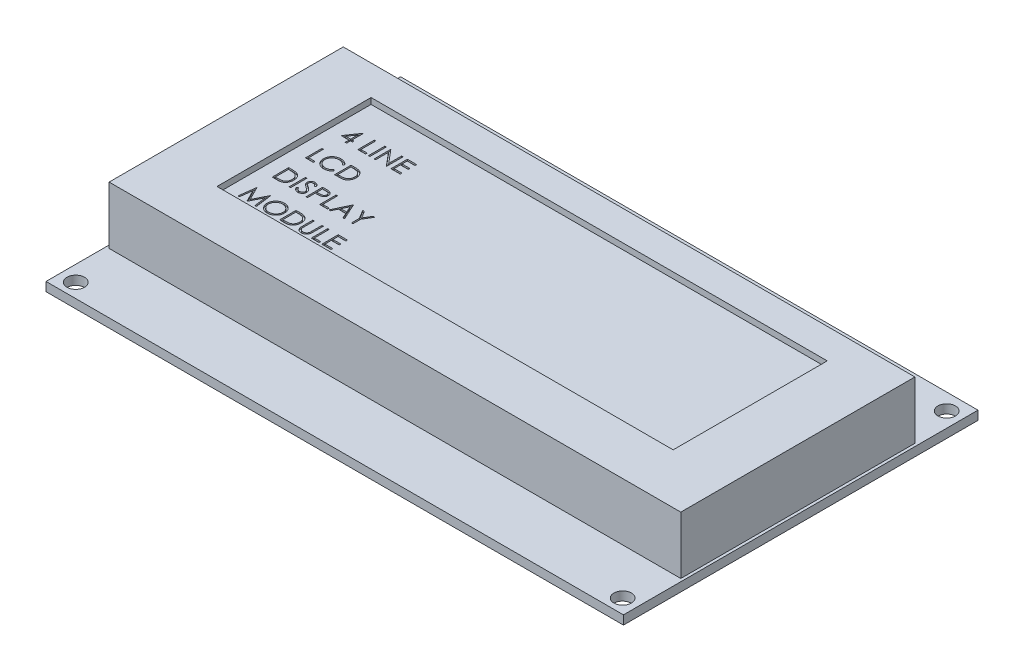
from build123d import *

# Parameters (mm, degrees)
SKETCH1_W           = 97.06
SKETCH1_H           = 39.75
BOSS_EXTRUDE1_DEPTH = 9.76
SKETCH3_W           = 98.044
SKETCH3_H           = 60.198
BOSS_EXTRUDE2_DEPTH = 1.51
SKETCH7_W           = 77.4512
SKETCH7_H           = 26.162
CUT_EXTRUDE3_DEPTH  = 1.016
SKETCH4_R           = 1.4859
CUT_EXTRUDE1_DEPTH  = 2.51
SKETCH5_W           = 0.25074359
SKETCH5_H           = 2.794
CUT_EXTRUDE2_DEPTH  = 0.254
SKETCH6_W           = 41.402
SKETCH6_H           = 2.54
BOSS_EXTRUDE3_DEPTH = 0.0254


with BuildPart() as part:
    # Sketch1 → Boss-Extrude1 (new body)
    with BuildSketch(Plane(origin=(0, 0, 0), x_dir=(1, 0, 0), z_dir=(0, 1, 0))):
        Rectangle(SKETCH1_W, SKETCH1_H)
    extrude(amount=BOSS_EXTRUDE1_DEPTH)

    # Sketch3 → Boss-Extrude2 (add)
    with BuildSketch(Plane.XZ):
        with Locations((-0.016, -0.0122)):
            Rectangle(SKETCH3_W, SKETCH3_H)
    extrude(amount=BOSS_EXTRUDE2_DEPTH)

    # Sketch7 → Cut-Extrude3 (cut)
    with BuildSketch(Plane(origin=(0, 9.76, 0), x_dir=(1, 0, 0), z_dir=(0, 1, 0))):
        with Locations((0, 1.714)):
            Rectangle(SKETCH7_W, SKETCH7_H)
    extrude(amount=-CUT_EXTRUDE3_DEPTH, mode=Mode.SUBTRACT)

    # Sketch4 → Cut-Extrude1 (cut, through all)
    with BuildSketch(Plane(origin=(0, 0, 0), x_dir=(1, 0, 0), z_dir=(0, 1, 0))):
        with Locations((-46.393991932, 27.334150115)):
            Circle(SKETCH4_R)
        with Locations((46.468408068, 27.334150115)):
            Circle(SKETCH4_R)
        with Locations((46.468408068, -27.682249885)):
            Circle(SKETCH4_R)
        with Locations((-46.393991932, -27.682249885)):
            Circle(SKETCH4_R)
    extrude(amount=-CUT_EXTRUDE1_DEPTH, mode=Mode.SUBTRACT)

    # Sketch5 → Cut-Extrude2 (cut)
    with BuildSketch(Plane(origin=(0, 8.744, 0), x_dir=(1, 0, 0), z_dir=(0, 1, 0))):
        Polygon((-35.159137095, 9.89153491), (-35.108204803, 9.89153491), (-35.108204803, 7.957227218), (-34.785820188, 7.957227218), (-34.785820188, 7.670663115), (-35.108204803, 7.670663115), (-35.108204803, 7.025893884), (-35.358948393, 7.025893884), (-35.358948393, 7.670663115), (-36.684307367, 7.670663115), align=None)
        Polygon((-35.358948393, 7.957227218), (-35.358948393, 9.170647089), (-36.191775316, 7.957227218), align=None, mode=Mode.SUBTRACT)
        Polygon((-33.209717624, 9.819893884), (-32.958974034, 9.819893884), (-32.958974034, 7.312457987), (-31.884358649, 7.312457987), (-31.884358649, 7.025893884), (-33.209717624, 7.025893884), align=None)
        with Locations((-31.293320188, 8.422893884)):
            Rectangle(SKETCH5_W, SKETCH5_H)
        Polygon((-30.451538137, 7.025893884), (-30.451538137, 9.819893884), (-30.398926758, 9.819893884), (-28.553050957, 7.620850214), (-28.553050957, 9.819893884), (-28.302307367, 9.819893884), (-28.302307367, 7.025893884), (-28.35939631, 7.025893884), (-30.200794547, 9.219900294), (-30.200794547, 7.025893884), align=None)
        Polygon((-27.585897111, 9.819893884), (-26.009794547, 9.819893884), (-26.009794547, 9.533329782), (-27.335153521, 9.533329782), (-27.335153521, 8.673637474), (-26.009794547, 8.673637474), (-26.009794547, 8.387073371), (-27.335153521, 8.387073371), (-27.335153521, 7.312457987), (-26.009794547, 7.312457987), (-26.009794547, 7.025893884), (-27.585897111, 7.025893884), align=None)
        Polygon((-36.433563778, 4.163227218), (-36.182820188, 4.163227218), (-36.182820188, 1.65579132), (-35.108204803, 1.65579132), (-35.108204803, 1.369227218), (-36.433563778, 1.369227218), align=None)
        with BuildLine():
            Line((-32.063461214, 3.650546128), (-32.282861855, 3.482637474))
            add(Edge.make_bspline(
                [(-32.282861855, 3.482637474), (-32.298512955, 3.501290194), (-32.329604146, 3.538344155), (-32.379624092, 3.590376054), (-32.43175346, 3.63912358), (-32.485972325, 3.684818954), (-32.543256605, 3.725864224), (-32.602218625, 3.764398356), (-32.663844722, 3.798938373), (-32.749063106, 3.840818825), (-32.860541989, 3.884521899), (-33.000876497, 3.921165793), (-33.147370786, 3.94449264), (-33.247314241, 3.947019087), (-33.298149515, 3.948304141)],
                knots=[0, 0, 0, 0, 7.3031e-05, 0.000145078, 0.000216355, 0.000287085, 0.000357615, 0.000427631, 0.000498304, 0.000569392, 0.000712408, 0.000856584, 0.001003817, 0.001156228, 0.001156228, 0.001156228, 0.001156228], degree=3))
            add(Edge.make_bspline(
                [(-33.298149515, 3.948304141), (-33.326156012, 3.947981663), (-33.381909078, 3.947339701), (-33.464650174, 3.938870588), (-33.54584625, 3.926967182), (-33.625444489, 3.909304852), (-33.70334357, 3.88697471), (-33.780052762, 3.86029168), (-33.854461452, 3.827278702), (-33.927598983, 3.790790451), (-33.997671873, 3.749576999), (-34.063973531, 3.704622855), (-34.126262144, 3.656431068), (-34.184586983, 3.604821013), (-34.239007676, 3.550025117), (-34.289129889, 3.491459411), (-34.334780185, 3.429311133), (-34.376863433, 3.364399801), (-34.414552683, 3.29691449), (-34.446108821, 3.226605419), (-34.47405291, 3.154676601), (-34.49616482, 3.08031536), (-34.513666849, 3.004044935), (-34.525743046, 2.925660632), (-34.534115843, 2.845326203), (-34.534754613, 2.790875683), (-34.535076598, 2.76342874)],
                knots=[0, 0, 0, 0, 8.3984e-05, 0.000167189, 0.000249274, 0.000330075, 0.000411568, 0.000492289, 0.000573499, 0.000655599, 0.000737383, 0.000817175, 0.000895765, 0.000973481, 0.001050656, 0.001127268, 0.001204508, 0.001281821, 0.001359234, 0.001436126, 0.001512837, 0.00159057, 0.001668641, 0.001747407, 0.001828384, 0.001910689, 0.001910689, 0.001910689, 0.001910689], degree=3))
            add(Edge.make_bspline(
                [(-34.535076598, 2.76342874), (-34.534069306, 2.722132366), (-34.532091622, 2.641052414), (-34.514490752, 2.522290961), (-34.487744116, 2.408518743), (-34.447657738, 2.300446949), (-34.398228645, 2.196742963), (-34.335770282, 2.099161432), (-34.263432395, 2.006227752), (-34.180191615, 1.920138267), (-34.088863087, 1.841496168), (-33.990875183, 1.772244418), (-33.886471954, 1.71451648), (-33.776806153, 1.666478882), (-33.661033878, 1.629552797), (-33.539363318, 1.603557322), (-33.412059103, 1.586599993), (-33.325070387, 1.584976529), (-33.280798954, 1.584150294)],
                knots=[0, 0, 0, 0, 0.000123819, 0.000243103, 0.00035944, 0.000473821, 0.000588219, 0.000703435, 0.000820659, 0.000940995, 0.001062046, 0.001181765, 0.001300276, 0.001419334, 0.001540405, 0.001664128, 0.001792211, 0.001924955, 0.001924955, 0.001924955, 0.001924955], degree=3))
            add(Edge.make_bspline(
                [(-33.280798954, 1.584150294), (-33.23202155, 1.585498423), (-33.136015951, 1.588151863), (-32.995223875, 1.610630989), (-32.860444696, 1.647079053), (-32.731671162, 1.698087851), (-32.609266305, 1.764397684), (-32.493038571, 1.844783361), (-32.382889854, 1.940009533), (-32.316655065, 2.012719893), (-32.282861855, 2.049816961)],
                knots=[0, 0, 0, 0, 0.000146262, 0.000287878, 0.000426504, 0.000564423, 0.000702406, 0.00084322, 0.000987646, 0.001138088, 0.001138088, 0.001138088, 0.001138088], degree=3))
            Line((-32.282861855, 2.049816961), (-32.063461214, 1.883587394))
            add(Edge.make_bspline(
                [(-32.063461214, 1.883587394), (-32.081117785, 1.860805555), (-32.116346353, 1.815351002), (-32.173390267, 1.751271243), (-32.233483058, 1.69099745), (-32.297071074, 1.635015572), (-32.363422819, 1.582205407), (-32.433729688, 1.534067317), (-32.507067424, 1.489929394), (-32.583187543, 1.449514643), (-32.662009167, 1.413657846), (-32.74343785, 1.382960753), (-32.827122601, 1.356517627), (-32.913067245, 1.334762795), (-33.001450052, 1.317782393), (-33.091952082, 1.306431029), (-33.184768662, 1.298654198), (-33.247387328, 1.297945388), (-33.279119867, 1.297586192)],
                knots=[0, 0, 0, 0, 8.6449e-05, 0.000172484, 0.000257177, 0.000341632, 0.000426509, 0.000511429, 0.00059705, 0.000683178, 0.000769844, 0.000856642, 0.000944087, 0.001033001, 0.001122463, 0.001213892, 0.001306528, 0.001401703, 0.001401703, 0.001401703, 0.001401703], degree=3))
            add(Edge.make_bspline(
                [(-33.279119867, 1.297586192), (-33.309170269, 1.297795337), (-33.368591217, 1.298208895), (-33.456321821, 1.304908242), (-33.541730074, 1.314048404), (-33.624571876, 1.327810954), (-33.705299297, 1.34405155), (-33.783180518, 1.365821805), (-33.858981906, 1.390208768), (-33.932398918, 1.418871206), (-34.003494004, 1.451214696), (-34.072037858, 1.487769443), (-34.137998956, 1.528228052), (-34.202025797, 1.571698708), (-34.263172554, 1.619577732), (-34.321969111, 1.671200182), (-34.378745168, 1.726392068), (-34.413871883, 1.766190486), (-34.431532928, 1.786200375)],
                knots=[0, 0, 0, 0, 9.0127e-05, 0.000178214, 0.000263818, 0.000347735, 0.000430062, 0.000510714, 0.000590185, 0.000668866, 0.000747009, 0.000824379, 0.000901746, 0.000979057, 0.001056421, 0.001134556, 0.001213713, 0.001293755, 0.001293755, 0.001293755, 0.001293755], degree=3))
            add(Edge.make_bspline(
                [(-34.431532928, 1.786200375), (-34.459820696, 1.820958684), (-34.516054718, 1.890055669), (-34.588000763, 2.002043964), (-34.649586554, 2.118967443), (-34.699380361, 2.24144038), (-34.738306954, 2.369187957), (-34.765274, 2.502274571), (-34.782797652, 2.640575928), (-34.78480158, 2.734643353), (-34.785820188, 2.782458387)],
                knots=[0, 0, 0, 0, 0.000134356, 0.00026709, 0.000398523, 0.000530313, 0.000663104, 0.000798557, 0.000937262, 0.001080654, 0.001080654, 0.001080654, 0.001080654], degree=3))
            add(Edge.make_bspline(
                [(-34.785820188, 2.782458387), (-34.784578699, 2.832714827), (-34.782136147, 2.931591233), (-34.761384075, 3.076698783), (-34.728000728, 3.215721357), (-34.68058504, 3.348399432), (-34.620469854, 3.475430862), (-34.546208037, 3.595845241), (-34.458662324, 3.710412651), (-34.358519323, 3.817394713), (-34.248701284, 3.915216128), (-34.13109878, 4.00127628), (-34.005941991, 4.072896491), (-33.874609741, 4.132764856), (-33.736118599, 4.178781608), (-33.590764047, 4.21099498), (-33.43881921, 4.231045615), (-33.335151891, 4.233580338), (-33.28247804, 4.234868243)],
                knots=[0, 0, 0, 0, 0.000150708, 0.000296508, 0.000438773, 0.000578979, 0.000718425, 0.000859629, 0.001002581, 0.001150291, 0.001298563, 0.001443203, 0.00158663, 0.001730409, 0.001875542, 0.002023548, 0.002176485, 0.002334462, 0.002334462, 0.002334462, 0.002334462], degree=3))
            add(Edge.make_bspline(
                [(-33.28247804, 4.234868243), (-33.250375402, 4.234483359), (-33.186831462, 4.23372152), (-33.092831202, 4.22629256), (-33.00131387, 4.213908269), (-32.912216418, 4.197051613), (-32.825105392, 4.176130682), (-32.740646571, 4.14887697), (-32.658344362, 4.117714665), (-32.57871783, 4.081824963), (-32.502149019, 4.041538085), (-32.428661775, 3.997300584), (-32.358839827, 3.949167304), (-32.292191872, 3.897547615), (-32.229832817, 3.841349451), (-32.16999214, 3.78211857), (-32.11470201, 3.718148883), (-32.080572746, 3.67312163), (-32.063461214, 3.650546128)],
                knots=[0, 0, 0, 0, 9.6294e-05, 0.000190604, 0.000282661, 0.000373223, 0.000462545, 0.000551226, 0.000639269, 0.000726445, 0.000813068, 0.000898689, 0.000983609, 0.001067354, 0.001151391, 0.001235293, 0.0013198, 0.001404772, 0.001404772, 0.001404772, 0.001404772], degree=3))
        make_face()
        with BuildLine():
            Line((-31.490333008, 1.369227218), (-31.490333008, 4.163227218))
            Line((-31.490333008, 4.163227218), (-30.926159932, 4.163227218))
            add(Edge.make_bspline(
                [(-30.926159932, 4.163227218), (-30.877090116, 4.16287392), (-30.782287489, 4.162191352), (-30.645291724, 4.157863533), (-30.518536914, 4.150207601), (-30.402439941, 4.139055928), (-30.296682082, 4.125362906), (-30.201559467, 4.10819944), (-30.116580242, 4.087932426), (-30.064316923, 4.070653173), (-30.039602239, 4.062482025)],
                knots=[0, 0, 0, 0, 0.000147209, 0.000284408, 0.000411142, 0.000528095, 0.000634244, 0.000730962, 0.000817976, 0.000896039, 0.000896039, 0.000896039, 0.000896039], degree=3))
            add(Edge.make_bspline(
                [(-30.039602239, 4.062482025), (-30.007275867, 4.050163913), (-29.943356178, 4.025807024), (-29.852345921, 3.97986065), (-29.766669617, 3.927801963), (-29.68586782, 3.86956234), (-29.611786246, 3.803492743), (-29.541530799, 3.732399744), (-29.477975502, 3.65369808), (-29.419773851, 3.569019933), (-29.367298013, 3.479362826), (-29.32168464, 3.384897599), (-29.283802795, 3.286103988), (-29.252355745, 3.18325673), (-29.227571801, 3.076129678), (-29.210662568, 2.964598095), (-29.199509726, 2.849102765), (-29.198388892, 2.770731493), (-29.197820188, 2.7309664)],
                knots=[0, 0, 0, 0, 0.000103725, 0.000205098, 0.00030531, 0.000404275, 0.000503418, 0.000602762, 0.000703812, 0.000806432, 0.000910777, 0.001015164, 0.001120767, 0.00122788, 0.001337582, 0.001450305, 0.001566091, 0.001685354, 0.001685354, 0.001685354, 0.001685354], degree=3))
            add(Edge.make_bspline(
                [(-29.197820188, 2.7309664), (-29.198322284, 2.696431572), (-29.199311716, 2.628377085), (-29.20819609, 2.528079753), (-29.221109415, 2.43075789), (-29.24110184, 2.33687494), (-29.265371732, 2.245608357), (-29.296476258, 2.157930845), (-29.332108137, 2.073038101), (-29.373658811, 1.992077979), (-29.419273963, 1.915375996), (-29.468226234, 1.843070846), (-29.520463413, 1.776194283), (-29.576483618, 1.714543785), (-29.635562921, 1.658212292), (-29.698088115, 1.606729237), (-29.764220539, 1.561101976), (-29.833663991, 1.519537547), (-29.908444306, 1.483279126), (-29.989977909, 1.452600999), (-30.078612512, 1.427178301), (-30.174130557, 1.405967134), (-30.276697082, 1.389141424), (-30.386412645, 1.377864527), (-30.503108677, 1.370238557), (-30.58324001, 1.369570877), (-30.62448405, 1.369227218)],
                knots=[0, 0, 0, 0, 0.000103581, 0.000204118, 0.000301873, 0.00039792, 0.000491876, 0.000584984, 0.000676776, 0.000767889, 0.000857734, 0.000944357, 0.001029673, 0.001112087, 0.001194034, 0.00127437, 0.001354795, 0.001434849, 0.001516954, 0.001603752, 0.001695856, 0.001793352, 0.001897144, 0.002007472, 0.002124116, 0.002247829, 0.002247829, 0.002247829, 0.002247829], degree=3))
            Line((-30.62448405, 1.369227218), (-31.490333008, 1.369227218))
        make_face()
        with BuildLine():
            Line((-31.239589419, 1.65579132), (-30.91888389, 1.65579132))
            add(Edge.make_bspline(
                [(-30.91888389, 1.65579132), (-30.872800156, 1.655989372), (-30.784164259, 1.656370298), (-30.656711561, 1.659712882), (-30.540258123, 1.665174703), (-30.434787409, 1.672818351), (-30.340358971, 1.682931526), (-30.256775463, 1.694207234), (-30.184310871, 1.708255027), (-30.140461487, 1.72098845), (-30.120198393, 1.72687265)],
                knots=[0, 0, 0, 0, 0.000138249, 0.000265904, 0.000382455, 0.000487969, 0.000583093, 0.000667312, 0.000740964, 0.00080424, 0.00080424, 0.00080424, 0.00080424], degree=3))
            add(Edge.make_bspline(
                [(-30.120198393, 1.72687265), (-30.094694472, 1.735854608), (-30.044295791, 1.753603991), (-29.971746719, 1.785980592), (-29.904086413, 1.82433189), (-29.840135724, 1.866962163), (-29.780801817, 1.915375), (-29.725381536, 1.968517669), (-29.673986464, 2.02666063), (-29.627147602, 2.089731716), (-29.585230973, 2.15733837), (-29.54893194, 2.228815942), (-29.517119032, 2.303381264), (-29.492149778, 2.382179376), (-29.472579338, 2.46450583), (-29.458717355, 2.550366418), (-29.450084115, 2.639745107), (-29.449077119, 2.70053626), (-29.448563778, 2.731526096)],
                knots=[0, 0, 0, 0, 8.11e-05, 0.000160263, 0.000237948, 0.000314167, 0.000390565, 0.000467359, 0.000544284, 0.00062309, 0.000702768, 0.000782618, 0.000863387, 0.000945693, 0.001030268, 0.001117037, 0.001206424, 0.001299375, 0.001299375, 0.001299375, 0.001299375], degree=3))
            add(Edge.make_bspline(
                [(-29.448563778, 2.731526096), (-29.448973528, 2.764202708), (-29.449778485, 2.828396203), (-29.459896206, 2.922586489), (-29.474681699, 3.013176472), (-29.496062733, 3.100172208), (-29.523308926, 3.183743424), (-29.55731162, 3.263427913), (-29.596161487, 3.340067228), (-29.642384894, 3.411892479), (-29.693008656, 3.479821093), (-29.749190312, 3.542051388), (-29.810037276, 3.598725124), (-29.874885896, 3.650724907), (-29.945563797, 3.695958709), (-30.020406029, 3.736421163), (-30.100510545, 3.770760134), (-30.156241023, 3.789024004), (-30.184563377, 3.798305743)],
                knots=[0, 0, 0, 0, 9.7987e-05, 0.000192496, 0.000283865, 0.000373187, 0.000460975, 0.000547256, 0.000632865, 0.000718418, 0.000803156, 0.000886776, 0.000969537, 0.001052402, 0.001135769, 0.001220909, 0.001307408, 0.001396793, 0.001396793, 0.001396793, 0.001396793], degree=3))
            add(Edge.make_bspline(
                [(-30.184563377, 3.798305743), (-30.207993978, 3.804784972), (-30.257813864, 3.818561589), (-30.339110853, 3.833589615), (-30.43060649, 3.846844749), (-30.532706994, 3.858067081), (-30.645295981, 3.866119646), (-30.768460042, 3.872163718), (-30.902252412, 3.87624027), (-30.994999269, 3.876518638), (-31.043136294, 3.876663115)],
                knots=[0, 0, 0, 0, 7.29e-05, 0.000155006, 0.000247774, 0.000350251, 0.000463063, 0.00058635, 0.000720174, 0.00086458, 0.00086458, 0.00086458, 0.00086458], degree=3))
            Line((-31.043136294, 3.876663115), (-31.239589419, 3.876663115))
            Line((-31.239589419, 3.876663115), (-31.239589419, 1.65579132))
        make_face(mode=Mode.SUBTRACT)
        with BuildLine():
            Line((-36.433563778, -4.287439449), (-36.433563778, -1.493439449))
            Line((-36.433563778, -1.493439449), (-35.869390701, -1.493439449))
            add(Edge.make_bspline(
                [(-35.869390701, -1.493439449), (-35.820320886, -1.493792746), (-35.725518258, -1.494475315), (-35.588522493, -1.498803134), (-35.461767684, -1.506459066), (-35.34567071, -1.517610739), (-35.239912851, -1.531303761), (-35.144790236, -1.548467226), (-35.059811011, -1.56873424), (-35.007547692, -1.586013494), (-34.982833008, -1.594184641)],
                knots=[0, 0, 0, 0, 0.000147209, 0.000284408, 0.000411142, 0.000528095, 0.000634244, 0.000730962, 0.000817976, 0.000896039, 0.000896039, 0.000896039, 0.000896039], degree=3))
            add(Edge.make_bspline(
                [(-34.982833008, -1.594184641), (-34.950506637, -1.606502753), (-34.886586948, -1.630859643), (-34.79557669, -1.676806016), (-34.709900386, -1.728864704), (-34.629098589, -1.787104327), (-34.555017015, -1.853173924), (-34.484761568, -1.924266923), (-34.421206272, -2.002968587), (-34.36300462, -2.087646734), (-34.310528783, -2.177303841), (-34.264915409, -2.271769068), (-34.227033564, -2.370562679), (-34.195586514, -2.473409937), (-34.170802571, -2.580536988), (-34.153893337, -2.692068572), (-34.142740495, -2.807563902), (-34.141619661, -2.885935174), (-34.141050957, -2.925700266)],
                knots=[0, 0, 0, 0, 0.000103725, 0.000205098, 0.00030531, 0.000404275, 0.000503418, 0.000602762, 0.000703812, 0.000806432, 0.000910777, 0.001015164, 0.001120767, 0.00122788, 0.001337582, 0.001450305, 0.001566091, 0.001685354, 0.001685354, 0.001685354, 0.001685354], degree=3))
            add(Edge.make_bspline(
                [(-34.141050957, -2.925700266), (-34.141553053, -2.960235095), (-34.142542485, -3.028289582), (-34.151426859, -3.128586914), (-34.164340184, -3.225908777), (-34.184332609, -3.319791727), (-34.208602502, -3.41105831), (-34.239707027, -3.498735821), (-34.275338906, -3.583628565), (-34.31688958, -3.664588687), (-34.362504732, -3.741290671), (-34.411457003, -3.813595821), (-34.463694182, -3.880472384), (-34.519714388, -3.942122882), (-34.57879369, -3.998454375), (-34.641318885, -4.049937429), (-34.707451309, -4.095564691), (-34.77689476, -4.137129119), (-34.851675076, -4.17338754), (-34.933208678, -4.204065668), (-35.021843282, -4.229488366), (-35.117361326, -4.250699533), (-35.219927851, -4.267525242), (-35.329643414, -4.27880214), (-35.446339446, -4.286428109), (-35.526470779, -4.28709579), (-35.567714819, -4.287439449)],
                knots=[0, 0, 0, 0, 0.000103581, 0.000204118, 0.000301873, 0.00039792, 0.000491876, 0.000584984, 0.000676776, 0.000767889, 0.000857734, 0.000944357, 0.001029673, 0.001112087, 0.001194034, 0.00127437, 0.001354795, 0.001434849, 0.001516954, 0.001603752, 0.001695856, 0.001793352, 0.001897144, 0.002007472, 0.002124116, 0.002247829, 0.002247829, 0.002247829, 0.002247829], degree=3))
            Line((-35.567714819, -4.287439449), (-36.433563778, -4.287439449))
        make_face()
        with BuildLine():
            Line((-36.182820188, -4.000875347), (-35.862114659, -4.000875347))
            add(Edge.make_bspline(
                [(-35.862114659, -4.000875347), (-35.816030925, -4.000677295), (-35.727395029, -4.000296369), (-35.59994233, -3.996953784), (-35.483488892, -3.991491963), (-35.378018178, -3.983848315), (-35.28358974, -3.973735141), (-35.200006232, -3.962459433), (-35.127541641, -3.948411639), (-35.083692256, -3.935678216), (-35.063429162, -3.929794016)],
                knots=[0, 0, 0, 0, 0.000138249, 0.000265904, 0.000382455, 0.000487969, 0.000583093, 0.000667312, 0.000740964, 0.00080424, 0.00080424, 0.00080424, 0.00080424], degree=3))
            add(Edge.make_bspline(
                [(-35.063429162, -3.929794016), (-35.037925241, -3.920812058), (-34.98752656, -3.903062676), (-34.914977488, -3.870686074), (-34.847317182, -3.832334776), (-34.783366493, -3.789704504), (-34.724032586, -3.741291667), (-34.668612306, -3.688148997), (-34.617217233, -3.630006037), (-34.570378371, -3.56693495), (-34.528461742, -3.499328296), (-34.49216271, -3.427850724), (-34.460349801, -3.353285402), (-34.435380548, -3.274487291), (-34.415810107, -3.192160837), (-34.401948125, -3.106300248), (-34.393314885, -3.01692156), (-34.392307889, -2.956130407), (-34.391794547, -2.925140571)],
                knots=[0, 0, 0, 0, 8.11e-05, 0.000160263, 0.000237948, 0.000314167, 0.000390565, 0.000467359, 0.000544284, 0.00062309, 0.000702768, 0.000782618, 0.000863387, 0.000945693, 0.001030268, 0.001117037, 0.001206424, 0.001299375, 0.001299375, 0.001299375, 0.001299375], degree=3))
            add(Edge.make_bspline(
                [(-34.391794547, -2.925140571), (-34.392204297, -2.892463958), (-34.393009254, -2.828270464), (-34.403126975, -2.734080177), (-34.417912468, -2.643490195), (-34.439293502, -2.556494459), (-34.466539695, -2.472923243), (-34.500542389, -2.393238754), (-34.539392256, -2.316599438), (-34.585615663, -2.244774187), (-34.636239425, -2.176845574), (-34.692421081, -2.114615279), (-34.753268045, -2.057941543), (-34.818116665, -2.00594176), (-34.888794567, -1.960707957), (-34.963636799, -1.920245504), (-35.043741314, -1.885906532), (-35.099471792, -1.867642663), (-35.127794146, -1.858360923)],
                knots=[0, 0, 0, 0, 9.7987e-05, 0.000192496, 0.000283865, 0.000373187, 0.000460975, 0.000547256, 0.000632865, 0.000718418, 0.000803156, 0.000886776, 0.000969537, 0.001052402, 0.001135769, 0.001220909, 0.001307408, 0.001396793, 0.001396793, 0.001396793, 0.001396793], degree=3))
            add(Edge.make_bspline(
                [(-35.127794146, -1.858360923), (-35.151224747, -1.851881695), (-35.201044633, -1.838105078), (-35.282341622, -1.823077052), (-35.373837259, -1.809821917), (-35.475937763, -1.798599585), (-35.58852675, -1.790547021), (-35.711690811, -1.784502949), (-35.845483181, -1.780426397), (-35.938230038, -1.780148029), (-35.986367063, -1.780003552)],
                knots=[0, 0, 0, 0, 7.29e-05, 0.000155006, 0.000247774, 0.000350251, 0.000463063, 0.00058635, 0.000720174, 0.00086458, 0.00086458, 0.00086458, 0.00086458], degree=3))
            Line((-35.986367063, -1.780003552), (-36.182820188, -1.780003552))
            Line((-36.182820188, -1.780003552), (-36.182820188, -4.000875347))
        make_face(mode=Mode.SUBTRACT)
        with Locations((-33.442550957, -2.890439449)):
            Rectangle(SKETCH5_W, SKETCH5_H)
        with BuildLine():
            Line((-32.887333008, -3.74845267), (-32.651141502, -3.606849706))
            add(Edge.make_bspline(
                [(-32.651141502, -3.606849706), (-32.629174086, -3.643622246), (-32.587085366, -3.714077014), (-32.516875052, -3.809279004), (-32.444124951, -3.890194966), (-32.368296323, -3.956354178), (-32.28985202, -4.008441432), (-32.20827995, -4.045324014), (-32.123855001, -4.068327395), (-32.066399327, -4.071121464), (-32.03771522, -4.072516372)],
                knots=[0, 0, 0, 0, 0.000128445, 0.000246096, 0.000354262, 0.000454248, 0.000547235, 0.000635662, 0.000721866, 0.000807808, 0.000807808, 0.000807808, 0.000807808], degree=3))
            add(Edge.make_bspline(
                [(-32.03771522, -4.072516372), (-32.013218338, -4.071834099), (-31.964653211, -4.070481492), (-31.893156952, -4.05748476), (-31.823720622, -4.037517935), (-31.757775326, -4.008922597), (-31.696230998, -3.974326103), (-31.642261539, -3.932538897), (-31.595604842, -3.885754401), (-31.557439509, -3.833560361), (-31.528158361, -3.777427186), (-31.505653035, -3.719810155), (-31.493163797, -3.659804161), (-31.491282434, -3.619402552), (-31.490333008, -3.599013968)],
                knots=[0, 0, 0, 0, 7.3425e-05, 0.000145565, 0.000217295, 0.000289758, 0.000360707, 0.000428548, 0.00049385, 0.000558332, 0.000621677, 0.000683319, 0.000743364, 0.000804534, 0.000804534, 0.000804534, 0.000804534], degree=3))
            add(Edge.make_bspline(
                [(-31.490333008, -3.599013968), (-31.49150993, -3.575751244), (-31.493902438, -3.528461526), (-31.514124197, -3.458691631), (-31.545935282, -3.389645848), (-31.575282375, -3.346936552), (-31.590518505, -3.324763167)],
                knots=[0, 0, 0, 0, 6.9675e-05, 0.000141639, 0.000216263, 0.000296838, 0.000296838, 0.000296838, 0.000296838], degree=3))
            add(Edge.make_bspline(
                [(-31.590518505, -3.324763167), (-31.603028133, -3.308760074), (-31.629290531, -3.275163582), (-31.674439585, -3.225154786), (-31.727418706, -3.173570825), (-31.786414858, -3.118441967), (-31.853577101, -3.062332223), (-31.926801865, -3.002565946), (-32.007958672, -2.941416001), (-32.064876041, -2.900406016), (-32.094244467, -2.879245539)],
                knots=[0, 0, 0, 0, 6.0925e-05, 0.000127904, 0.000201913, 0.000282711, 0.00037007, 0.000464386, 0.000566252, 0.000674846, 0.000674846, 0.000674846, 0.000674846], degree=3))
            add(Edge.make_bspline(
                [(-32.094244467, -2.879245539), (-32.123640537, -2.858307632), (-32.179843584, -2.818275949), (-32.258441664, -2.758864106), (-32.328726301, -2.704545657), (-32.390385105, -2.654809254), (-32.443390954, -2.609648152), (-32.48816154, -2.569496026), (-32.523556377, -2.533266977), (-32.543238575, -2.509764375), (-32.552075396, -2.499212286)],
                knots=[0, 0, 0, 0, 0.000108266, 0.000206996, 0.000295552, 0.000374747, 0.000444621, 0.000504446, 0.00055511, 0.000596391, 0.000596391, 0.000596391, 0.000596391], degree=3))
            add(Edge.make_bspline(
                [(-32.552075396, -2.499212286), (-32.564426908, -2.482766772), (-32.588717814, -2.450424463), (-32.620781762, -2.399873134), (-32.648034568, -2.348125647), (-32.669398555, -2.295042948), (-32.687388897, -2.241370265), (-32.699489257, -2.186407299), (-32.707066103, -2.130400676), (-32.707842026, -2.092710813), (-32.708230444, -2.073843696)],
                knots=[0, 0, 0, 0, 6.1683e-05, 0.000121309, 0.000179388, 0.000236865, 0.000292795, 0.000349011, 0.000405451, 0.000462025, 0.000462025, 0.000462025, 0.000462025], degree=3))
            add(Edge.make_bspline(
                [(-32.708230444, -2.073843696), (-32.707188515, -2.044283356), (-32.705126926, -1.985794507), (-32.687691953, -1.900353324), (-32.660172734, -1.818779367), (-32.621619615, -1.741880238), (-32.57192046, -1.671658252), (-32.514407188, -1.607305657), (-32.445905104, -1.553206966), (-32.37074441, -1.505938826), (-32.28847598, -1.468941536), (-32.202268385, -1.441032685), (-32.111984608, -1.425219237), (-32.05083342, -1.422949899), (-32.019804964, -1.421798423)],
                knots=[0, 0, 0, 0, 8.8609e-05, 0.000175324, 0.000260458, 0.000346313, 0.000432331, 0.000517908, 0.00060427, 0.000693261, 0.000783679, 0.00087413, 0.000964491, 0.001057569, 0.001057569, 0.001057569, 0.001057569], degree=3))
            add(Edge.make_bspline(
                [(-32.019804964, -1.421798423), (-31.986880387, -1.422934026), (-31.921403914, -1.425192377), (-31.825091369, -1.444828235), (-31.732361928, -1.477319), (-31.657767505, -1.514190746), (-31.599386666, -1.551016796), (-31.554864091, -1.584560621), (-31.509747017, -1.62317778), (-31.463671518, -1.666971132), (-31.417418318, -1.71634251), (-31.370300739, -1.770953785), (-31.3222086, -1.830471219), (-31.29127035, -1.872959578), (-31.275409932, -1.894741132)],
                knots=[0, 0, 0, 0, 9.8699e-05, 0.00019628, 0.000293456, 0.000392827, 0.000445155, 0.000500341, 0.000559895, 0.000623237, 0.000690942, 0.00076276, 0.000839593, 0.000920414, 0.000920414, 0.000920414, 0.000920414], degree=3))
            Line((-31.275409932, -1.894741132), (-31.502086614, -2.066567654))
            add(Edge.make_bspline(
                [(-31.502086614, -2.066567654), (-31.515773967, -2.048934568), (-31.542132609, -2.014977367), (-31.582150262, -1.967422437), (-31.619868183, -1.923982539), (-31.657028702, -1.886251462), (-31.691669218, -1.852162959), (-31.725290651, -1.822977828), (-31.757409159, -1.79841011), (-31.797895744, -1.772191565), (-31.848760688, -1.746202173), (-31.912611201, -1.724210138), (-31.97933693, -1.710994468), (-32.024783042, -1.709247111), (-32.047789739, -1.708362526)],
                knots=[0, 0, 0, 0, 6.6958e-05, 0.000128945, 0.000186442, 0.00023948, 0.00028777, 0.000332208, 0.000372955, 0.000408971, 0.000476806, 0.000543712, 0.000610999, 0.000679987, 0.000679987, 0.000679987, 0.000679987], degree=3))
            add(Edge.make_bspline(
                [(-32.047789739, -1.708362526), (-32.076652975, -1.709329809), (-32.132313005, -1.711195122), (-32.211335496, -1.731567362), (-32.282457904, -1.763643967), (-32.343568723, -1.80859941), (-32.394449041, -1.861861825), (-32.43125437, -1.923153288), (-32.45340693, -1.990833869), (-32.456110149, -2.038045808), (-32.457486855, -2.06209009)],
                knots=[0, 0, 0, 0, 8.6413e-05, 0.000166639, 0.000243022, 0.000319149, 0.0003928, 0.000462582, 0.000531966, 0.000603976, 0.000603976, 0.000603976, 0.000603976], degree=3))
            add(Edge.make_bspline(
                [(-32.457486855, -2.06209009), (-32.457173027, -2.077059128), (-32.456544859, -2.10702168), (-32.447783835, -2.151287758), (-32.436528542, -2.19544201), (-32.418692738, -2.239285923), (-32.394069373, -2.283586277), (-32.36173467, -2.329105916), (-32.321011472, -2.376246051), (-32.289816851, -2.406906109), (-32.273347031, -2.423093696)],
                knots=[0, 0, 0, 0, 4.4832e-05, 8.9736e-05, 0.000134947, 0.000181405, 0.000231256, 0.000286691, 0.000348613, 0.000417873, 0.000417873, 0.000417873, 0.000417873], degree=3))
            add(Edge.make_bspline(
                [(-32.273347031, -2.423093696), (-32.267231067, -2.428551596), (-32.252700936, -2.441518317), (-32.22613724, -2.462746555), (-32.191058332, -2.488932539), (-32.14838022, -2.521332814), (-32.097315989, -2.558917273), (-32.037860023, -2.601205351), (-31.970675074, -2.649569857), (-31.922999922, -2.683383277), (-31.897791342, -2.701262366)],
                knots=[0, 0, 0, 0, 2.4588e-05, 5.8416e-05, 0.000101961, 0.000155916, 0.000219164, 0.000292165, 0.000374796, 0.000467511, 0.000467511, 0.000467511, 0.000467511], degree=3))
            add(Edge.make_bspline(
                [(-31.897791342, -2.701262366), (-31.86746773, -2.723328068), (-31.808750258, -2.766055243), (-31.725203607, -2.830249931), (-31.649451236, -2.893033321), (-31.581227181, -2.954004474), (-31.519857443, -3.0127009), (-31.466022874, -3.069828765), (-31.419174934, -3.124978791), (-31.368739867, -3.195685012), (-31.317204282, -3.282523398), (-31.272946118, -3.388917512), (-31.245039369, -3.495725203), (-31.241389993, -3.567512512), (-31.239589419, -3.602931837)],
                knots=[0, 0, 0, 0, 0.000112504, 0.000217849, 0.000316026, 0.000407592, 0.0004923, 0.000570698, 0.000643005, 0.000709174, 0.000831085, 0.000945005, 0.001054009, 0.00116017, 0.00116017, 0.00116017, 0.00116017], degree=3))
            add(Edge.make_bspline(
                [(-31.239589419, -3.602931837), (-31.240114003, -3.627980738), (-31.241152984, -3.677592106), (-31.253096067, -3.75043973), (-31.270594223, -3.821192487), (-31.296967375, -3.888975815), (-31.329156776, -3.955029777), (-31.370002061, -4.017621684), (-31.417346538, -4.078136849), (-31.471656921, -4.134961613), (-31.531086021, -4.187126548), (-31.59389809, -4.233530148), (-31.660195937, -4.272221718), (-31.729619905, -4.30379459), (-31.802185942, -4.328488375), (-31.877869641, -4.346380248), (-31.95679576, -4.357361236), (-32.010440944, -4.358500997), (-32.03771522, -4.359080475)],
                knots=[0, 0, 0, 0, 7.5074e-05, 0.000148691, 0.000220909, 0.000293361, 0.00036645, 0.000440971, 0.000517108, 0.000596682, 0.000676397, 0.000754087, 0.000830594, 0.000906236, 0.000982521, 0.001060173, 0.001139249, 0.001221034, 0.001221034, 0.001221034, 0.001221034], degree=3))
            add(Edge.make_bspline(
                [(-32.03771522, -4.359080475), (-32.058818177, -4.358672406), (-32.10075832, -4.357861407), (-32.162792689, -4.350691779), (-32.223573836, -4.34054788), (-32.282339065, -4.324443208), (-32.339845502, -4.304903587), (-32.395843037, -4.280844587), (-32.45035881, -4.252012741), (-32.503698332, -4.219047512), (-32.555725944, -4.180683701), (-32.605953657, -4.136000859), (-32.656029469, -4.086231333), (-32.704475351, -4.030023586), (-32.752271227, -3.968285699), (-32.798474734, -3.900440048), (-32.844042254, -3.826856184), (-32.87263323, -3.775075312), (-32.887333008, -3.74845267)],
                knots=[0, 0, 0, 0, 6.3285e-05, 0.000125773, 0.000187149, 0.00024797, 0.000308327, 0.000369251, 0.000430589, 0.000493179, 0.00055721, 0.000624236, 0.000694682, 0.000768869, 0.000846674, 0.000928799, 0.001015003, 0.001106225, 0.001106225, 0.001106225, 0.001106225], degree=3))
        make_face()
        with BuildLine():
            Line((-30.666461214, -1.493439449), (-30.118519307, -1.493439449))
            add(Edge.make_bspline(
                [(-30.118519307, -1.493439449), (-30.080831515, -1.493480877), (-30.008620032, -1.493560255), (-29.905070356, -1.495966884), (-29.81102453, -1.499181334), (-29.72668534, -1.50363728), (-29.651793289, -1.508903244), (-29.586687262, -1.516289015), (-29.530855513, -1.524000691), (-29.497402193, -1.531840979), (-29.482145508, -1.535416613)],
                knots=[0, 0, 0, 0, 0.00011306, 0.000216628, 0.000310717, 0.000395349, 0.000469999, 0.000535886, 0.000591928, 0.000638916, 0.000638916, 0.000638916, 0.000638916], degree=3))
            add(Edge.make_bspline(
                [(-29.482145508, -1.535416613), (-29.462832156, -1.540702821), (-29.424660546, -1.551150674), (-29.369657828, -1.572076715), (-29.317327129, -1.596889163), (-29.267488908, -1.625167588), (-29.2207556, -1.658125264), (-29.176429954, -1.694426204), (-29.134903147, -1.734908524), (-29.096408699, -1.779118178), (-29.061056778, -1.826312997), (-29.030618397, -1.877197508), (-29.005131347, -1.930915195), (-28.983271673, -1.987428691), (-28.967538695, -2.047212566), (-28.955686627, -2.109851422), (-28.94816388, -2.175338543), (-28.947443378, -2.220090335), (-28.947076598, -2.242871741)],
                knots=[0, 0, 0, 0, 6.0044e-05, 0.000118673, 0.000176257, 0.000233669, 0.000290342, 0.000347601, 0.000405388, 0.000464094, 0.000523311, 0.000582055, 0.000641636, 0.00070151, 0.000763558, 0.000826786, 0.000892674, 0.000960993, 0.000960993, 0.000960993, 0.000960993], degree=3))
            add(Edge.make_bspline(
                [(-28.947076598, -2.242871741), (-28.947413016, -2.265844629), (-28.948071239, -2.310792636), (-28.955971302, -2.376549656), (-28.966612604, -2.439389422), (-28.982975108, -2.499172601), (-29.004405625, -2.555544162), (-29.029545281, -2.609365568), (-29.05986699, -2.659721169), (-29.094708035, -2.706793776), (-29.133466079, -2.750627575), (-29.175977139, -2.790904917), (-29.222069591, -2.827390037), (-29.271596951, -2.86016473), (-29.325042059, -2.888468971), (-29.381594338, -2.913820374), (-29.44174534, -2.935111501), (-29.483369964, -2.946311498), (-29.504533329, -2.952005956)],
                knots=[0, 0, 0, 0, 6.8879e-05, 0.000134766, 0.000198444, 0.000259952, 0.00032035, 0.000379184, 0.000437928, 0.000496362, 0.000554649, 0.000613243, 0.000671808, 0.000730797, 0.000791146, 0.000853032, 0.000916584, 0.000982316, 0.000982316, 0.000982316, 0.000982316], degree=3))
            add(Edge.make_bspline(
                [(-29.504533329, -2.952005956), (-29.522037606, -2.955728347), (-29.560399248, -2.963886183), (-29.623577753, -2.972993392), (-29.697136098, -2.980766779), (-29.780973884, -2.986595173), (-29.875015856, -2.991584753), (-29.979312889, -2.995550711), (-30.094069715, -2.997729914), (-30.174114817, -2.997842307), (-30.215906326, -2.997900988)],
                knots=[0, 0, 0, 0, 5.3675e-05, 0.000117633, 0.00019137, 0.00027555, 0.000369714, 0.000473891, 0.00058865, 0.000714023, 0.000714023, 0.000714023, 0.000714023], degree=3))
            Line((-30.215906326, -2.997900988), (-30.415717624, -2.997900988))
            Line((-30.415717624, -2.997900988), (-30.415717624, -4.287439449))
            Line((-30.415717624, -4.287439449), (-30.666461214, -4.287439449))
            Line((-30.666461214, -4.287439449), (-30.666461214, -1.493439449))
        make_face()
        with BuildLine():
            Line((-30.415717624, -1.780003552), (-30.415717624, -2.711336885))
            Line((-30.415717624, -2.711336885), (-29.926543746, -2.717493536))
            add(Edge.make_bspline(
                [(-29.926543746, -2.717493536), (-29.902659096, -2.71750588), (-29.856550273, -2.717529711), (-29.789944328, -2.714348364), (-29.7281496, -2.710675824), (-29.671355902, -2.705298633), (-29.619537632, -2.697697949), (-29.572608387, -2.690025036), (-29.530932059, -2.678924583), (-29.482157439, -2.663978225), (-29.427807476, -2.638486874), (-29.36868041, -2.601486419), (-29.318571547, -2.554323133), (-29.275210027, -2.501294745), (-29.24079922, -2.442302125), (-29.215608523, -2.379182523), (-29.200807381, -2.312583262), (-29.198822689, -2.267010617), (-29.197820188, -2.243991132)],
                knots=[0, 0, 0, 0, 7.1643e-05, 0.000138306, 0.000199997, 0.000257359, 0.000309363, 0.000357121, 0.000399882, 0.000438647, 0.000510027, 0.000579269, 0.000647001, 0.000715445, 0.000784176, 0.000851005, 0.000918633, 0.00098766, 0.00098766, 0.00098766, 0.00098766], degree=3))
            add(Edge.make_bspline(
                [(-29.197820188, -2.243991132), (-29.198828141, -2.221528559), (-29.200831826, -2.176875743), (-29.215724535, -2.111433269), (-29.240750244, -2.048978824), (-29.275441023, -1.990725453), (-29.317543513, -1.937887876), (-29.366477903, -1.891988741), (-29.422129004, -1.855090616), (-29.47389642, -1.831275133), (-29.519878624, -1.816734139), (-29.559818423, -1.806560115), (-29.604914122, -1.798437074), (-29.6551804, -1.791859597), (-29.710227656, -1.786228919), (-29.770528813, -1.782408342), (-29.835855442, -1.78017198), (-29.881206509, -1.780061054), (-29.904715621, -1.780003552)],
                knots=[0, 0, 0, 0, 6.7352e-05, 0.000133888, 0.000200197, 0.000268445, 0.000336537, 0.000402277, 0.000468872, 0.000535991, 0.000572453, 0.000613448, 0.000659554, 0.000709818, 0.00076551, 0.000825525, 0.000891048, 0.000961572, 0.000961572, 0.000961572, 0.000961572], degree=3))
            Line((-29.904715621, -1.780003552), (-30.415717624, -1.780003552))
        make_face(mode=Mode.SUBTRACT)
        Polygon((-28.373948393, -1.493439449), (-28.123204803, -1.493439449), (-28.123204803, -4.000875347), (-27.048589419, -4.000875347), (-27.048589419, -4.287439449), (-28.373948393, -4.287439449), align=None)
        Polygon((-25.436666342, -1.493439449), (-24.14712788, -4.287439449), (-24.419699595, -4.287439449), (-24.832754883, -3.391926629), (-26.099345829, -3.391926629), (-26.524154723, -4.287439449), (-26.797845829, -4.287439449), (-25.472486855, -1.493439449), align=None)
        Polygon((-25.457375076, -2.038023183), (-25.963339819, -3.105362526), (-24.964843024, -3.105362526), align=None, mode=Mode.SUBTRACT)
        Polygon((-23.860563778, -1.493439449), (-23.57343998, -1.493439449), (-22.839119467, -2.693986324), (-22.105918345, -1.493439449), (-21.818794547, -1.493439449), (-22.714307367, -2.959281997), (-22.714307367, -4.287439449), (-22.965050957, -4.287439449), (-22.965050957, -2.959281997), align=None)
        Polygon((-36.576845829, -9.944106116), (-36.208006486, -7.150106116), (-36.172185973, -7.150106116), (-35.018653521, -9.442618936), (-33.867919547, -7.150106116), (-33.831539339, -7.150106116), (-33.460461214, -9.944106116), (-33.712324194, -9.944106116), (-33.979858649, -7.933679834), (-34.988429964, -9.944106116), (-35.04495921, -9.944106116), (-36.057448393, -7.92920227), (-36.324423153, -9.944106116), align=None)
        with BuildLine():
            add(Edge.make_bspline(
                [(-31.57988429, -7.07846509), (-31.528148905, -7.07977546), (-31.426536341, -7.082349134), (-31.277197122, -7.102050109), (-31.134627209, -7.136133229), (-30.997665218, -7.181526136), (-30.867949396, -7.242079608), (-30.744503378, -7.315270552), (-30.627620879, -7.40186576), (-30.518877296, -7.501195834), (-30.419365433, -7.609270511), (-30.331692997, -7.724605163), (-30.258216949, -7.846502435), (-30.197877895, -7.974596024), (-30.150540662, -8.108596238), (-30.117875574, -8.249217462), (-30.097009862, -8.395548574), (-30.094570479, -8.495355734), (-30.093333008, -8.545986725)],
                knots=[0, 0, 0, 0, 0.000155181, 0.000304788, 0.000450864, 0.000594404, 0.000736891, 0.000879433, 0.001024285, 0.001172472, 0.001320623, 0.001464466, 0.001606336, 0.001746794, 0.001888582, 0.002031805, 0.002179269, 0.002331095, 0.002331095, 0.002331095, 0.002331095], degree=3))
            add(Edge.make_bspline(
                [(-30.093333008, -8.545986725), (-30.094570297, -8.596244755), (-30.097009137, -8.695309154), (-30.117899299, -8.840711664), (-30.150661743, -8.980484066), (-30.197438305, -9.114393024), (-30.25748973, -9.242579799), (-30.331455029, -9.364707099), (-30.418580898, -9.480814961), (-30.517733453, -9.589631414), (-30.625822171, -9.689415109), (-30.741757418, -9.776363492), (-30.862931857, -9.851182121), (-30.990904807, -9.91088086), (-31.123979065, -9.95859593), (-31.263345639, -9.991128173), (-31.408351488, -10.012112744), (-31.507235941, -10.014522382), (-31.55749647, -10.015747141)],
                knots=[0, 0, 0, 0, 0.000150708, 0.000297063, 0.000439741, 0.000580817, 0.000721781, 0.00086365, 0.001008387, 0.001156575, 0.001304726, 0.001449016, 0.001590697, 0.001731155, 0.001871888, 0.002014022, 0.002159823, 0.00231053, 0.00231053, 0.00231053, 0.00231053], degree=3))
            add(Edge.make_bspline(
                [(-31.55749647, -10.015747141), (-31.608127198, -10.014510288), (-31.70793384, -10.012072121), (-31.854448833, -9.991171879), (-31.995168838, -9.958489021), (-32.129691437, -9.911781774), (-32.258091647, -9.851417619), (-32.380620587, -9.777812181), (-32.496786443, -9.690474023), (-32.605626112, -9.59135362), (-32.705211615, -9.483448101), (-32.79203267, -9.367828984), (-32.865654661, -9.2467646), (-32.925816133, -9.119918976), (-32.973445418, -8.987905316), (-33.005939493, -8.849843017), (-33.026963107, -8.706519195), (-33.029385782, -8.608934435), (-33.03061506, -8.559419417)],
                knots=[0, 0, 0, 0, 0.000151826, 0.00029929, 0.000443057, 0.000584661, 0.000725626, 0.000867975, 0.001012712, 0.001160899, 0.00130905, 0.001452556, 0.001593947, 0.001733393, 0.001873072, 0.002014117, 0.002158255, 0.002306726, 0.002306726, 0.002306726, 0.002306726], degree=3))
            add(Edge.make_bspline(
                [(-33.03061506, -8.559419417), (-33.030188268, -8.526184652), (-33.029340068, -8.460134393), (-33.019128643, -8.362051742), (-33.004311102, -8.265546457), (-32.983075175, -8.170892963), (-32.955301484, -8.078322965), (-32.922530237, -7.987198042), (-32.882504315, -7.898441664), (-32.837256964, -7.811633368), (-32.786755966, -7.728126371), (-32.730975153, -7.649192212), (-32.671873776, -7.574168525), (-32.607082199, -7.50499946), (-32.538735814, -7.439672821), (-32.465725897, -7.379192526), (-32.388497945, -7.323013208), (-32.306719657, -7.272385656), (-32.222406097, -7.226596678), (-32.135491321, -7.187303578), (-32.04715576, -7.15357915), (-31.956985679, -7.126245189), (-31.865220523, -7.1046659), (-31.771660013, -7.089971573), (-31.676378684, -7.079734103), (-31.612187477, -7.078889914), (-31.57988429, -7.07846509)],
                knots=[0, 0, 0, 0, 9.9665e-05, 0.000198073, 0.000295519, 0.00039247, 0.000488806, 0.000585302, 0.000682763, 0.000780648, 0.000878843, 0.00097527, 0.00107046, 0.001165115, 0.001259336, 0.00135393, 0.001449315, 0.001545604, 0.001642267, 0.001736947, 0.001831541, 0.001925733, 0.002019409, 0.002114092, 0.002209715, 0.002306583, 0.002306583, 0.002306583, 0.002306583], degree=3))
        make_face()
        with BuildLine():
            add(Edge.make_bspline(
                [(-31.567570989, -7.365029193), (-31.594085757, -7.365352411), (-31.646861809, -7.365995757), (-31.72532095, -7.374470131), (-31.802748225, -7.386548105), (-31.879159624, -7.403776325), (-31.954235434, -7.42724916), (-32.02867545, -7.454263874), (-32.101800859, -7.487170082), (-32.173370253, -7.524348406), (-32.242753316, -7.565499173), (-32.308222884, -7.610978921), (-32.369948446, -7.659721093), (-32.427778871, -7.711839441), (-32.481544349, -7.76759938), (-32.532303108, -7.826155582), (-32.578020597, -7.889181748), (-32.619919083, -7.954968799), (-32.657412839, -8.023431044), (-32.690753525, -8.093847717), (-32.718026165, -8.166793219), (-32.740268302, -8.241476166), (-32.758708551, -8.317778278), (-32.770390604, -8.396278382), (-32.778958093, -8.476582023), (-32.779564667, -8.530850966), (-32.77987147, -8.558300026)],
                knots=[0, 0, 0, 0, 7.9508e-05, 0.000158256, 0.00023647, 0.000314541, 0.000392972, 0.000472303, 0.000551976, 0.000633335, 0.000714156, 0.000793802, 0.000872297, 0.000949968, 0.001027151, 0.001104553, 0.001182244, 0.0012605, 0.001338402, 0.001416272, 0.001494029, 0.001571763, 0.00164996, 0.001729279, 0.001809698, 0.001892004, 0.001892004, 0.001892004, 0.001892004], degree=3))
            add(Edge.make_bspline(
                [(-32.77987147, -8.558300026), (-32.778853766, -8.598663125), (-32.776851627, -8.678069826), (-32.759323213, -8.794434453), (-32.732323614, -8.906264931), (-32.69252319, -9.012949358), (-32.642749585, -9.115404765), (-32.581260119, -9.212722264), (-32.508409295, -9.304928155), (-32.425656182, -9.391378721), (-32.335192285, -9.470285914), (-32.239132385, -9.539547904), (-32.138505591, -9.598150258), (-32.033049492, -9.645891793), (-31.923327085, -9.683722343), (-31.808631348, -9.709649571), (-31.689726324, -9.726713291), (-31.608675853, -9.728351977), (-31.567570989, -9.729183039)],
                knots=[0, 0, 0, 0, 0.000121024, 0.000238091, 0.000352254, 0.000465584, 0.000578975, 0.000693419, 0.000810203, 0.000930943, 0.001051936, 0.001169832, 0.0012857, 0.001400668, 0.0015166, 0.001633224, 0.001752984, 0.00187622, 0.00187622, 0.00187622, 0.00187622], degree=3))
            add(Edge.make_bspline(
                [(-31.567570989, -9.729183039), (-31.539942718, -9.728803451), (-31.48514756, -9.728050613), (-31.403646163, -9.720467955), (-31.323613061, -9.708308571), (-31.245160511, -9.690801642), (-31.16837755, -9.668890929), (-31.092943699, -9.642860646), (-31.019662435, -9.610385422), (-30.947609296, -9.574504114), (-30.87864041, -9.533599829), (-30.812801371, -9.48966366), (-30.751751689, -9.440993281), (-30.693964527, -9.38964929), (-30.639978309, -9.334596436), (-30.590158109, -9.275906293), (-30.544671683, -9.213208408), (-30.502789107, -9.147521144), (-30.465426731, -9.078871564), (-30.432873359, -9.008199587), (-30.405255774, -8.935679234), (-30.382960847, -8.861205905), (-30.365489996, -8.784921045), (-30.353451911, -8.70672251), (-30.345031243, -8.626766738), (-30.344396545, -8.572687786), (-30.344076598, -8.545427029)],
                knots=[0, 0, 0, 0, 8.2865e-05, 0.000164347, 0.000245325, 0.00032558, 0.000405305, 0.000484783, 0.000564744, 0.000645592, 0.000726128, 0.000805142, 0.000882851, 0.000960148, 0.00103693, 0.001113969, 0.001190878, 0.001269133, 0.001347527, 0.001425161, 0.001502395, 0.001580128, 0.001658199, 0.001736965, 0.001817384, 0.001899131, 0.001899131, 0.001899131, 0.001899131], degree=3))
            add(Edge.make_bspline(
                [(-30.344076598, -8.545427029), (-30.344396801, -8.518352767), (-30.345031982, -8.46464598), (-30.353447889, -8.385247829), (-30.365502714, -8.30761198), (-30.382875573, -8.232043218), (-30.40526761, -8.158522281), (-30.432878182, -8.087118221), (-30.465436504, -8.017565027), (-30.50280284, -7.950034608), (-30.544805301, -7.885233975), (-30.590702134, -7.823285077), (-30.641285786, -7.765351295), (-30.695111018, -7.710002399), (-30.753522291, -7.658418861), (-30.81625501, -7.610583569), (-30.882547592, -7.565342103), (-30.952738648, -7.524529298), (-31.02517825, -7.48683885), (-31.099509792, -7.454547392), (-31.174891193, -7.42710862), (-31.251130762, -7.403705306), (-31.328870202, -7.386615581), (-31.40758423, -7.374459247), (-31.487163943, -7.365998707), (-31.540683588, -7.36535339), (-31.567570989, -7.365029193)],
                knots=[0, 0, 0, 0, 8.1187e-05, 0.000161049, 0.000239262, 0.000316788, 0.000393449, 0.000469638, 0.000546257, 0.000623669, 0.000700982, 0.000777773, 0.000854751, 0.000931533, 0.001009248, 0.001088282, 0.001168074, 0.001249858, 0.001331714, 0.001412923, 0.00149278, 0.001572282, 0.001651991, 0.00173131, 0.001811172, 0.001891799, 0.001891799, 0.001891799, 0.001891799], degree=3))
        make_face(mode=Mode.SUBTRACT)
        with BuildLine():
            Line((-29.520204803, -9.944106116), (-29.520204803, -7.150106116))
            Line((-29.520204803, -7.150106116), (-28.956031726, -7.150106116))
            add(Edge.make_bspline(
                [(-28.956031726, -7.150106116), (-28.906961911, -7.150459413), (-28.812159284, -7.151141982), (-28.675163519, -7.155469801), (-28.548408709, -7.163125733), (-28.432311735, -7.174277406), (-28.326553877, -7.187970427), (-28.231431262, -7.205133893), (-28.146452037, -7.225400907), (-28.094188718, -7.242680161), (-28.069474034, -7.250851308)],
                knots=[0, 0, 0, 0, 0.000147209, 0.000284408, 0.000411142, 0.000528095, 0.000634244, 0.000730962, 0.000817976, 0.000896039, 0.000896039, 0.000896039, 0.000896039], degree=3))
            add(Edge.make_bspline(
                [(-28.069474034, -7.250851308), (-28.037147662, -7.26316942), (-27.973227973, -7.28752631), (-27.882217716, -7.333472683), (-27.796541412, -7.38553137), (-27.715739615, -7.443770993), (-27.641658041, -7.50984059), (-27.571402594, -7.58093359), (-27.507847297, -7.659635253), (-27.449645646, -7.744313401), (-27.397169808, -7.833970508), (-27.351556435, -7.928435734), (-27.31367459, -8.027229346), (-27.28222754, -8.130076604), (-27.257443596, -8.237203655), (-27.240534363, -8.348735238), (-27.229381521, -8.464230569), (-27.228260687, -8.54260184), (-27.227691983, -8.582366933)],
                knots=[0, 0, 0, 0, 0.000103725, 0.000205098, 0.00030531, 0.000404275, 0.000503418, 0.000602762, 0.000703812, 0.000806432, 0.000910777, 0.001015164, 0.001120767, 0.00122788, 0.001337582, 0.001450305, 0.001566091, 0.001685354, 0.001685354, 0.001685354, 0.001685354], degree=3))
            add(Edge.make_bspline(
                [(-27.227691983, -8.582366933), (-27.228194079, -8.616901762), (-27.229183511, -8.684956249), (-27.238067885, -8.785253581), (-27.25098121, -8.882575443), (-27.270973635, -8.976458393), (-27.295243527, -9.067724977), (-27.326348053, -9.155402488), (-27.361979932, -9.240295232), (-27.403530606, -9.321255354), (-27.449145757, -9.397957338), (-27.498098029, -9.470262488), (-27.550335208, -9.537139051), (-27.606355413, -9.598789548), (-27.665434716, -9.655121041), (-27.72795991, -9.706604096), (-27.794092334, -9.752231357), (-27.863535785, -9.793795786), (-27.938316101, -9.830054207), (-28.019849704, -9.860732335), (-28.108484307, -9.886155033), (-28.204002352, -9.907366199), (-28.306568877, -9.924191909), (-28.41628444, -9.935468806), (-28.532980471, -9.943094776), (-28.613111805, -9.943762457), (-28.654355845, -9.944106116)],
                knots=[0, 0, 0, 0, 0.000103581, 0.000204118, 0.000301873, 0.00039792, 0.000491876, 0.000584984, 0.000676776, 0.000767889, 0.000857734, 0.000944357, 0.001029673, 0.001112087, 0.001194034, 0.00127437, 0.001354795, 0.001434849, 0.001516954, 0.001603752, 0.001695856, 0.001793352, 0.001897144, 0.002007472, 0.002124116, 0.002247829, 0.002247829, 0.002247829, 0.002247829], degree=3))
            Line((-28.654355845, -9.944106116), (-29.520204803, -9.944106116))
        make_face()
        with BuildLine():
            Line((-29.269461214, -9.657542013), (-28.948755685, -9.657542013))
            add(Edge.make_bspline(
                [(-28.948755685, -9.657542013), (-28.902671951, -9.657343961), (-28.814036054, -9.656963035), (-28.686583356, -9.653620451), (-28.570129918, -9.64815863), (-28.464659204, -9.640514982), (-28.370230766, -9.630401808), (-28.286647258, -9.619126099), (-28.214182666, -9.605078306), (-28.170333281, -9.592344883), (-28.150070188, -9.586460683)],
                knots=[0, 0, 0, 0, 0.000138249, 0.000265904, 0.000382455, 0.000487969, 0.000583093, 0.000667312, 0.000740964, 0.00080424, 0.00080424, 0.00080424, 0.00080424], degree=3))
            add(Edge.make_bspline(
                [(-28.150070188, -9.586460683), (-28.124566267, -9.577478725), (-28.074167585, -9.559729342), (-28.001618513, -9.527352741), (-27.933958207, -9.489001443), (-27.870007519, -9.44637117), (-27.810673611, -9.397958333), (-27.755253331, -9.344815664), (-27.703858259, -9.286672704), (-27.657019397, -9.223601617), (-27.615102768, -9.155994963), (-27.578803735, -9.084517391), (-27.546990827, -9.009952069), (-27.522021573, -8.931153958), (-27.502451133, -8.848827504), (-27.48858915, -8.762966915), (-27.47995591, -8.673588227), (-27.478948914, -8.612797074), (-27.478435573, -8.581807238)],
                knots=[0, 0, 0, 0, 8.11e-05, 0.000160263, 0.000237948, 0.000314167, 0.000390565, 0.000467359, 0.000544284, 0.00062309, 0.000702768, 0.000782618, 0.000863387, 0.000945693, 0.001030268, 0.001117037, 0.001206424, 0.001299375, 0.001299375, 0.001299375, 0.001299375], degree=3))
            add(Edge.make_bspline(
                [(-27.478435573, -8.581807238), (-27.478845323, -8.549130625), (-27.47965028, -8.48493713), (-27.489768001, -8.390746844), (-27.504553494, -8.300156862), (-27.525934528, -8.213161125), (-27.553180721, -8.129589909), (-27.587183415, -8.04990542), (-27.626033282, -7.973266105), (-27.672256689, -7.901440854), (-27.722880451, -7.833512241), (-27.779062106, -7.771281945), (-27.839909071, -7.71460821), (-27.904757691, -7.662608427), (-27.975435592, -7.617374624), (-28.050277824, -7.57691217), (-28.13038234, -7.542573199), (-28.186112818, -7.52430933), (-28.214435172, -7.51502759)],
                knots=[0, 0, 0, 0, 9.7987e-05, 0.000192496, 0.000283865, 0.000373187, 0.000460975, 0.000547256, 0.000632865, 0.000718418, 0.000803156, 0.000886776, 0.000969537, 0.001052402, 0.001135769, 0.001220909, 0.001307408, 0.001396793, 0.001396793, 0.001396793, 0.001396793], degree=3))
            add(Edge.make_bspline(
                [(-28.214435172, -7.51502759), (-28.237865773, -7.508548362), (-28.287685659, -7.494771744), (-28.368982648, -7.479743718), (-28.460478285, -7.466488584), (-28.562578789, -7.455266252), (-28.675167776, -7.447213688), (-28.798331836, -7.441169615), (-28.932124207, -7.437093064), (-29.024871064, -7.436814696), (-29.073008089, -7.436670218)],
                knots=[0, 0, 0, 0, 7.29e-05, 0.000155006, 0.000247774, 0.000350251, 0.000463063, 0.00058635, 0.000720174, 0.00086458, 0.00086458, 0.00086458, 0.00086458], degree=3))
            Line((-29.073008089, -7.436670218), (-29.269461214, -7.436670218))
            Line((-29.269461214, -7.436670218), (-29.269461214, -9.657542013))
        make_face(mode=Mode.SUBTRACT)
        with BuildLine():
            Line((-26.654563778, -7.150106116), (-26.403820188, -7.150106116))
            Line((-26.403820188, -7.150106116), (-26.403820188, -8.824155395))
            add(Edge.make_bspline(
                [(-26.403820188, -8.824155395), (-26.403857503, -8.847849102), (-26.403928315, -8.892811995), (-26.403455319, -8.956809204), (-26.402130669, -9.01370499), (-26.401295535, -9.063718665), (-26.399437658, -9.106620733), (-26.397922474, -9.142643624), (-26.395974213, -9.171616767), (-26.393632747, -9.188525198), (-26.392626278, -9.195793215)],
                knots=[0, 0, 0, 0, 7.1081e-05, 0.000134889, 0.000191989, 0.000241814, 0.000284944, 0.000320804, 0.000349994, 0.000372, 0.000372, 0.000372, 0.000372], degree=3))
            add(Edge.make_bspline(
                [(-26.392626278, -9.195793215), (-26.388493186, -9.222014317), (-26.380459888, -9.272979056), (-26.359986751, -9.345549838), (-26.331394152, -9.410954551), (-26.297512477, -9.471234136), (-26.252862273, -9.524710785), (-26.199374308, -9.573974316), (-26.134571255, -9.617059237), (-26.062517503, -9.656455285), (-25.984856087, -9.688119353), (-25.905497494, -9.712062628), (-25.825634613, -9.726654412), (-25.772168497, -9.728344015), (-25.745618265, -9.729183039)],
                knots=[0, 0, 0, 0, 7.9597e-05, 0.000154709, 0.000225408, 0.000293373, 0.000361383, 0.000433481, 0.000510792, 0.000594189, 0.000679522, 0.000761866, 0.000842565, 0.000922167, 0.000922167, 0.000922167, 0.000922167], degree=3))
            add(Edge.make_bspline(
                [(-25.745618265, -9.729183039), (-25.722824222, -9.7283258), (-25.677367788, -9.726616272), (-25.609827683, -9.716029861), (-25.544048854, -9.696950381), (-25.479706482, -9.672331442), (-25.419395211, -9.639803223), (-25.363081389, -9.602227244), (-25.312818179, -9.55815319), (-25.266950281, -9.509377658), (-25.227008106, -9.454344001), (-25.192385543, -9.394250538), (-25.164025701, -9.328192917), (-25.150020956, -9.281769072), (-25.142826198, -9.257919417)],
                knots=[0, 0, 0, 0, 6.8395e-05, 0.000136395, 0.000204435, 0.000273552, 0.000342658, 0.000409564, 0.000476222, 0.000542753, 0.000610033, 0.000679732, 0.000750431, 0.000825125, 0.000825125, 0.000825125, 0.000825125], degree=3))
            add(Edge.make_bspline(
                [(-25.142826198, -9.257919417), (-25.14043124, -9.248061727), (-25.135094311, -9.22609482), (-25.130107384, -9.188957538), (-25.124913318, -9.145140143), (-25.121309401, -9.09432781), (-25.117795969, -9.036690805), (-25.115694025, -8.971928873), (-25.114722485, -8.900277173), (-25.114432963, -8.850274822), (-25.114281726, -8.824155395)],
                knots=[0, 0, 0, 0, 3.0415e-05, 6.7776e-05, 0.000112278, 0.000162803, 0.000220549, 0.000285513, 0.000357162, 0.000435522, 0.000435522, 0.000435522, 0.000435522], degree=3))
            Line((-25.114281726, -8.824155395), (-25.114281726, -7.150106116))
            Line((-25.114281726, -7.150106116), (-24.863538137, -7.150106116))
            Line((-24.863538137, -7.150106116), (-24.863538137, -8.837588087))
            add(Edge.make_bspline(
                [(-24.863538137, -8.837588087), (-24.863740997, -8.868001479), (-24.864136892, -8.927355062), (-24.867569981, -9.014329375), (-24.873043826, -9.096834584), (-24.880777688, -9.174881778), (-24.891025285, -9.248191675), (-24.902420989, -9.317406853), (-24.916933451, -9.38203047), (-24.933883771, -9.442566406), (-24.953260998, -9.50019107), (-24.978360018, -9.554880519), (-25.00663889, -9.608297328), (-25.040178587, -9.659633573), (-25.077866759, -9.709116552), (-25.120536473, -9.756446174), (-25.166776503, -9.802378773), (-25.217355534, -9.845736117), (-25.27143981, -9.885497673), (-25.328868451, -9.920460808), (-25.389200307, -9.950016233), (-25.45227855, -9.974344728), (-25.518130098, -9.992637125), (-25.586756614, -10.006267978), (-25.658314301, -10.014013183), (-25.706981515, -10.015164255), (-25.731625877, -10.015747141)],
                knots=[0, 0, 0, 0, 9.1237e-05, 0.000178055, 0.000261079, 0.00033927, 0.000413279, 0.000483118, 0.000549653, 0.00061185, 0.000671677, 0.000731802, 0.000792151, 0.000852851, 0.00091554, 0.000978567, 0.001043869, 0.001110951, 0.001178231, 0.001245039, 0.001312373, 0.00137952, 0.001447559, 0.001517151, 0.001589219, 0.001663152, 0.001663152, 0.001663152, 0.001663152], degree=3))
            add(Edge.make_bspline(
                [(-25.731625877, -10.015747141), (-25.758503441, -10.015120675), (-25.811237124, -10.013891549), (-25.888940713, -10.006848473), (-25.963432103, -9.993582247), (-26.035498046, -9.976690566), (-26.1041574, -9.953393605), (-26.170330053, -9.926173559), (-26.232882668, -9.892743541), (-26.292830037, -9.855548701), (-26.348570142, -9.813698861), (-26.399738183, -9.768084676), (-26.446418636, -9.719436844), (-26.487824675, -9.667228666), (-26.524642318, -9.611866189), (-26.55635838, -9.553192796), (-26.583590495, -9.491231203), (-26.597645566, -9.448161134), (-26.604750877, -9.426387766)],
                knots=[0, 0, 0, 0, 8.0645e-05, 0.000158225, 0.000233769, 0.000307481, 0.000380048, 0.000451043, 0.000521895, 0.000592554, 0.000662516, 0.000730702, 0.000798001, 0.00086452, 0.000930338, 0.000997207, 0.00106438, 0.001133056, 0.001133056, 0.001133056, 0.001133056], degree=3))
            add(Edge.make_bspline(
                [(-26.604750877, -9.426387766), (-26.608883728, -9.411513648), (-26.617847975, -9.379251355), (-26.627447599, -9.325856827), (-26.635517534, -9.264376918), (-26.643105685, -9.194807421), (-26.647583236, -9.117094414), (-26.651508757, -9.031271582), (-26.654591432, -8.937235152), (-26.654573254, -8.871732204), (-26.654563778, -8.837588087)],
                knots=[0, 0, 0, 0, 4.6293e-05, 0.00010041, 0.000162546, 0.000232329, 0.000310289, 0.000396012, 0.000490083, 0.000592508, 0.000592508, 0.000592508, 0.000592508], degree=3))
            Line((-26.654563778, -8.837588087), (-26.654563778, -7.150106116))
        make_face()
        Polygon((-24.14712788, -7.150106116), (-23.89638429, -7.150106116), (-23.89638429, -9.657542013), (-22.821768906, -9.657542013), (-22.821768906, -9.944106116), (-24.14712788, -9.944106116), align=None)
        Polygon((-22.356102239, -7.150106116), (-20.779999675, -7.150106116), (-20.779999675, -7.436670218), (-22.105358649, -7.436670218), (-22.105358649, -8.296362526), (-20.779999675, -8.296362526), (-20.779999675, -8.582926629), (-22.105358649, -8.582926629), (-22.105358649, -9.657542013), (-20.779999675, -9.657542013), (-20.779999675, -9.944106116), (-22.356102239, -9.944106116), align=None)
    extrude(amount=-CUT_EXTRUDE2_DEPTH, mode=Mode.SUBTRACT)

    # Sketch6 → Boss-Extrude3 (add)
    with BuildSketch(Plane.XZ.offset(1.51)):
        with Locations((-19.955, -27.1902)):
            Rectangle(SKETCH6_W, SKETCH6_H)
    extrude(amount=BOSS_EXTRUDE3_DEPTH)


solid = part.part
